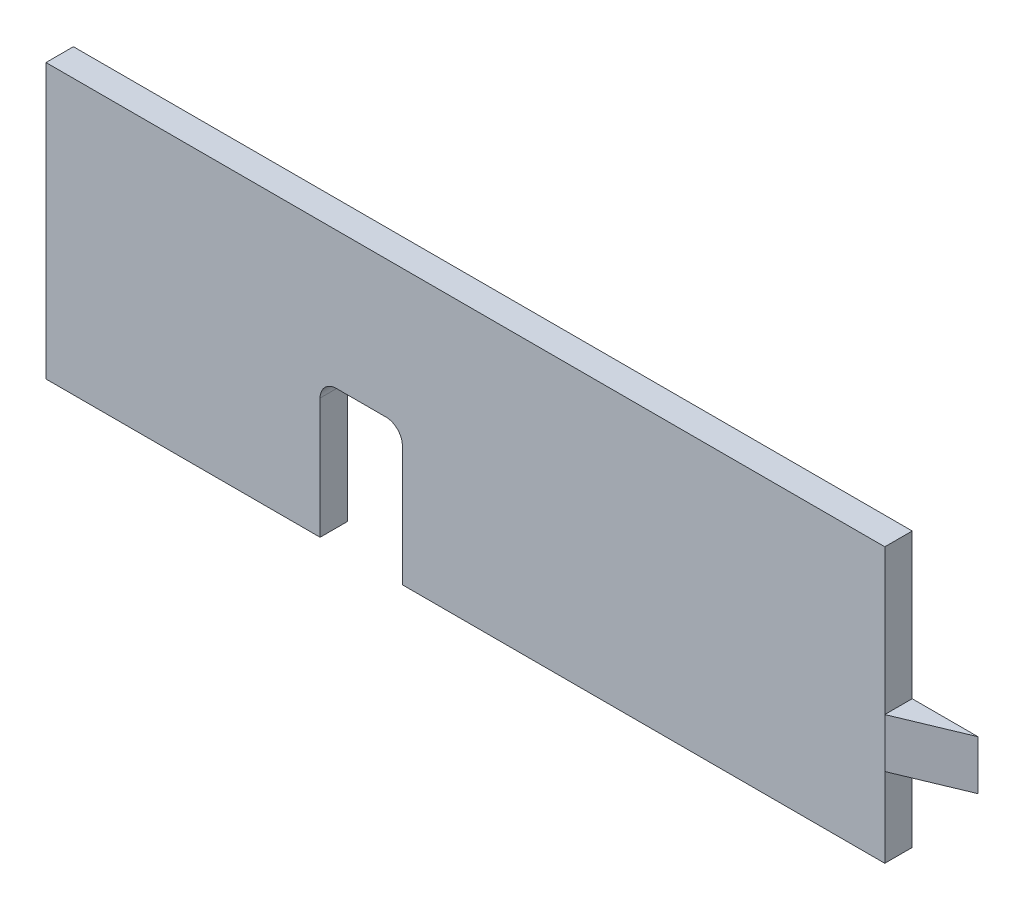
from build123d import *

# Parameters (mm, degrees)
SKETCH1_W           = 153
SKETCH1_H           = 50
BOSS_EXTRUDE1_DEPTH = 2.5
CUT_EXTRUDE1_DEPTH  = 6
SKETCH5_W           = 5
SKETCH5_H           = 9
BOSS_EXTRUDE2_DEPTH = 12
CUT_EXTRUDE2_DEPTH  = 9


with BuildPart() as part:
    # Sketch1 → Boss-Extrude1 (new body, symmetric)
    with BuildSketch(Plane.XY):
        Rectangle(SKETCH1_W, SKETCH1_H)
    extrude(amount=BOSS_EXTRUDE1_DEPTH, both=True)

    # Sketch2 → Cut-Extrude1 (cut, through all)
    with BuildSketch(Plane.XY.offset(2.5)):
        with BuildLine():
            Line((-26.5, -25), (-26.5, -3))
            ThreePointArc((-26.5, -3), (-25.621320344, -0.878679656), (-23.5, 0))
            Line((-23.5, 0), (-14.5, 0))
            ThreePointArc((-14.5, 0), (-12.378679656, -0.878679656), (-11.5, -3))
            Line((-11.5, -3), (-11.5, -25))
            Line((-11.5, -25), (-26.5, -25))
        make_face()
    extrude(amount=-CUT_EXTRUDE1_DEPTH, mode=Mode.SUBTRACT)

    # Sketch5 → Boss-Extrude2 (add)
    with BuildSketch(Plane(origin=(76.5, 0, 0), x_dir=(0, 0, -1), z_dir=(1, 0, 0))):
        with Locations((0, -6)):
            Rectangle(SKETCH5_W, SKETCH5_H)
    extrude(amount=BOSS_EXTRUDE2_DEPTH)

    # Sketch7 → Cut-Extrude2 (cut)
    with BuildSketch(Plane.XZ.offset(10.5)):
        Polygon((76.5, 2.5), (88.5, -2.5), (88.5, 2.5), align=None)
    extrude(amount=-CUT_EXTRUDE2_DEPTH, mode=Mode.SUBTRACT)


solid = part.part
